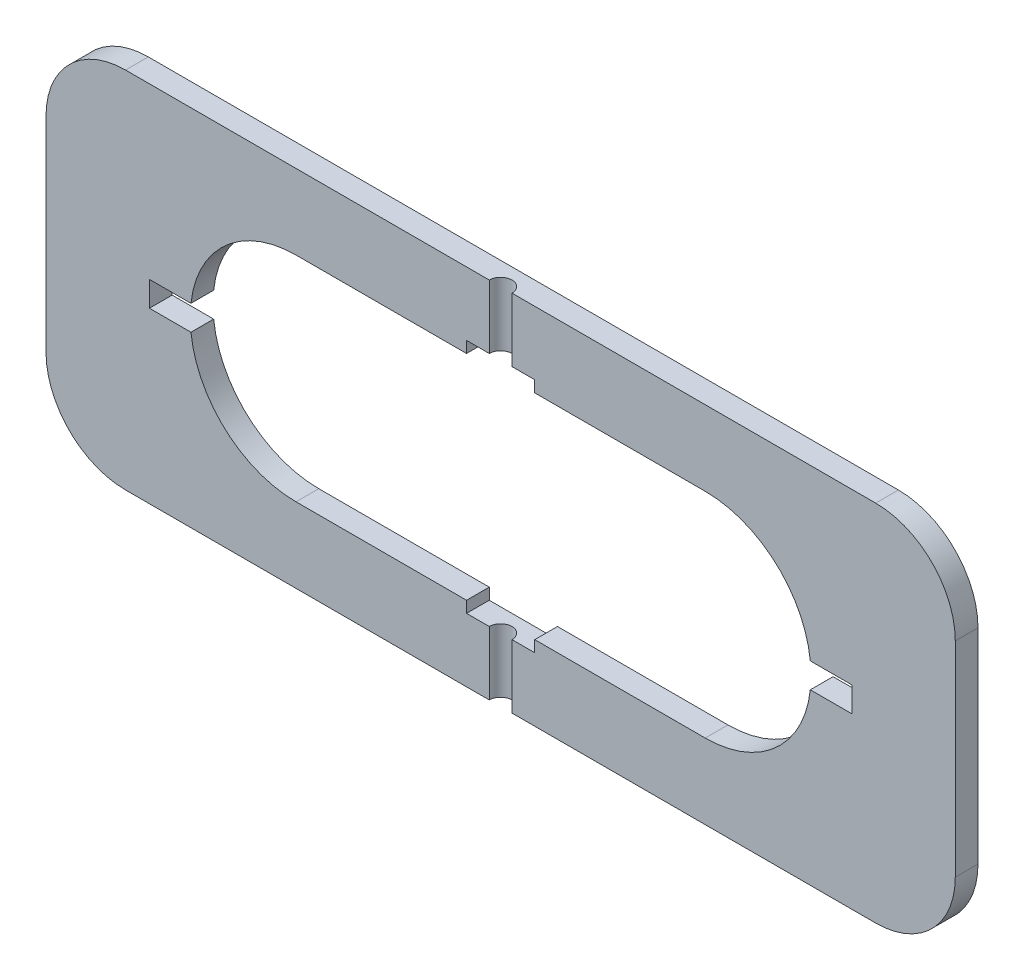
from build123d import *

# Parameters (mm, degrees)
BOSS_EXTRU_2_DEPTH      = 10
ENL_V_MAT_EXTRU_1_DEPTH = 10
ESQUISSE4_W             = 309
ESQUISSE4_H             = 11
ENL_V_MAT_EXTRU_2_DEPTH = 10
ESQUISSE5_W             = 30
ESQUISSE5_H             = 104
ENL_V_MAT_EXTRU_3_DEPTH = 10
ESQUISSE6_R             = 5
ENL_V_MAT_EXTRU_4_DEPTH = 161


with BuildPart() as part:
    # Esquisse2 → Boss.-Extru.2 (new body)
    with BuildSketch(Plane.XY):
        with BuildLine():
            Line((165, 80), (-165, 80))
            ThreePointArc((-165, 80), (-189.748737342, 69.748737342), (-200, 45))
            Line((-200, 45), (-200, -45))
            ThreePointArc((-200, -45), (-189.748737342, -69.748737342), (-165, -80))
            Line((-165, -80), (165, -80))
            ThreePointArc((165, -80), (189.748737342, -69.748737342), (200, -45))
            Line((200, -45), (200, 45))
            ThreePointArc((200, 45), (189.748737342, 69.748737342), (165, 80))
        make_face()
    extrude(amount=BOSS_EXTRU_2_DEPTH)

    # Esquisse3 → Enlèv. mat.-Extru.1 (cut)
    with BuildSketch(Plane.XY.offset(10)):
        with BuildLine():
            Line((90, 47), (-90, 47))
            ThreePointArc((-90, 47), (-122.880465325, 33.380465325), (-136.5, 0.5))
            Line((-136.5, 0.5), (-136.5, -0.5))
            ThreePointArc((-136.5, -0.5), (-122.880465325, -33.380465325), (-90, -47))
            Line((-90, -47), (90, -47))
            ThreePointArc((90, -47), (122.880465325, -33.380465325), (136.5, -0.5))
            Line((136.5, -0.5), (136.5, 0.5))
            ThreePointArc((136.5, 0.5), (122.880465325, 33.380465325), (90, 47))
        make_face()
    extrude(amount=-ENL_V_MAT_EXTRU_1_DEPTH, mode=Mode.SUBTRACT)

    # Esquisse4 → Enlèv. mat.-Extru.2 (cut)
    with BuildSketch(Plane.XY.offset(10)):
        Rectangle(ESQUISSE4_W, ESQUISSE4_H)
    extrude(amount=-ENL_V_MAT_EXTRU_2_DEPTH, mode=Mode.SUBTRACT)

    # Esquisse5 → Enlèv. mat.-Extru.3 (cut)
    with BuildSketch(Plane.XY.offset(10)):
        Rectangle(ESQUISSE5_W, ESQUISSE5_H)
    extrude(amount=-ENL_V_MAT_EXTRU_3_DEPTH, mode=Mode.SUBTRACT)

    # Esquisse6 → Enlèv. mat.-Extru.4 (cut, through all)
    with BuildSketch(Plane.XZ.offset(80)):
        with Locations((0, 10)):
            Circle(ESQUISSE6_R)
    extrude(amount=-ENL_V_MAT_EXTRU_4_DEPTH, mode=Mode.SUBTRACT)


solid = part.part
